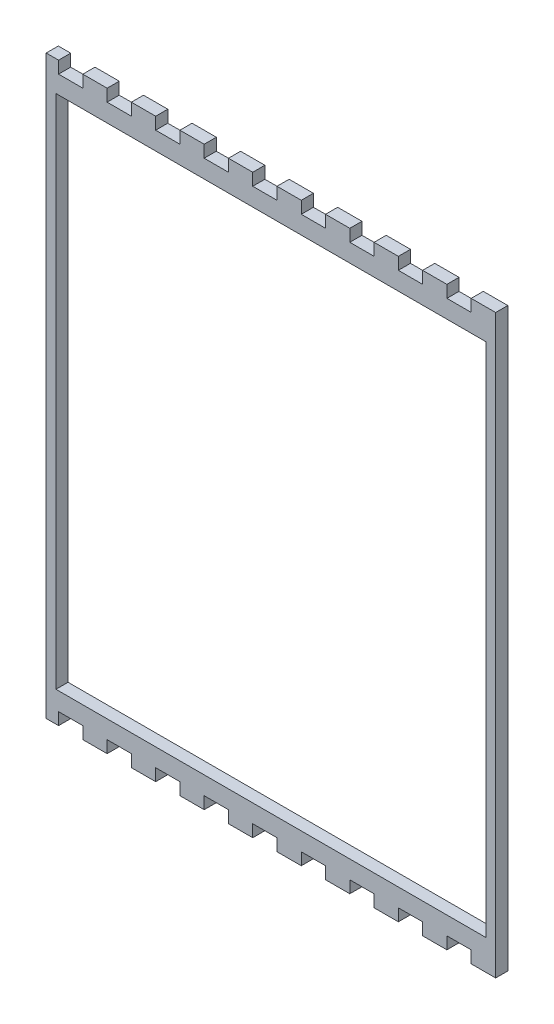
from build123d import *

# Parameters (mm, degrees)
BOSS_EXTRUDE1_DEPTH = 5.715
SKETCH2_W           = 202.5
SKETCH2_H           = 243
CUT_EXTRUDE1_DEPTH  = 6.715


with BuildPart() as part:
    # Model → Boss-Extrude1 (new body)
    with BuildSketch(Plane.XY):
        Polygon((1074.08036017, 22.860238699), (1079.905563672, 22.860238699), (1079.905563672, 28.575245224), (1091.332742073, 28.575245224), (1091.332742073, 22.860238699), (1102.763463785, 22.860238699), (1102.763463785, 28.575245224), (1114.194185497, 28.575245224), (1114.194185497, 22.860238699), (1125.62490721, 22.860238699), (1125.62490721, 28.575245224), (1137.055628922, 28.575245224), (1137.055628922, 22.860238699), (1148.482807323, 22.860238699), (1148.482807323, 28.575245224), (1159.913529035, 28.575245224), (1159.913529035, 22.860238699), (1171.344250747, 22.860238699), (1171.344250747, 28.575245224), (1182.77497246, 28.575245224), (1182.77497246, 22.860238699), (1194.205694172, 22.860238699), (1194.205694172, 28.575245224), (1205.632872573, 28.575245224), (1205.632872573, 22.860238699), (1217.063594285, 22.860238699), (1217.063594285, 28.575245224), (1228.494315997, 28.575245224), (1228.494315997, 22.860238699), (1239.92503771, 22.860238699), (1239.92503771, 28.575245224), (1251.355759422, 28.575245224), (1251.355759422, 22.860238699), (1262.782937823, 22.860238699), (1262.782937823, 28.575245224), (1274.213659535, 28.575245224), (1274.213659535, 22.860238699), (1280.038863036, 22.860238699), (1285.754223893, 22.860238699), (1285.754223893, 28.575245224), (1285.754223893, 288.575408216), (1285.754223893, 294.290414741), (1280.038863036, 294.290414741), (1274.213659535, 294.290414741), (1274.213659535, 288.575408216), (1262.782937823, 288.575408216), (1262.782937823, 294.290414741), (1251.355759422, 294.290414741), (1251.355759422, 288.575408216), (1239.92503771, 288.575408216), (1239.92503771, 294.290414741), (1228.494315997, 294.290414741), (1228.494315997, 288.575408216), (1217.063594285, 288.575408216), (1217.063594285, 294.290414741), (1205.632872573, 294.290414741), (1205.632872573, 288.575408216), (1194.205694172, 288.575408216), (1194.205694172, 294.290414741), (1182.77497246, 294.290414741), (1182.77497246, 288.575408216), (1171.344250747, 288.575408216), (1171.344250747, 294.290414741), (1159.913529035, 294.290414741), (1159.913529035, 288.575408216), (1148.482807323, 288.575408216), (1148.482807323, 294.290414741), (1137.055628922, 294.290414741), (1137.055628922, 288.575408216), (1125.62490721, 288.575408216), (1125.62490721, 294.290414741), (1114.194185497, 294.290414741), (1114.194185497, 288.575408216), (1102.763463785, 288.575408216), (1102.763463785, 294.290414741), (1091.332742073, 294.290414741), (1091.332742073, 288.575408216), (1079.905563672, 288.575408216), (1079.905563672, 294.290414741), (1074.08036017, 294.290414741), (1074.08036017, 288.575408216), (1074.08036017, 28.575245224), align=None)
    extrude(amount=BOSS_EXTRUDE1_DEPTH)

    # Sketch2 → Cut-Extrude1 (cut, through all)
    with BuildSketch(Plane(origin=(0, 0, 0), x_dir=(-1, 0, 0), z_dir=(0, 0, -1))):
        with Locations((-1179.917292032, 158.575323457)):
            Rectangle(SKETCH2_W, SKETCH2_H)
    extrude(amount=-CUT_EXTRUDE1_DEPTH, mode=Mode.SUBTRACT)


solid = part.part
